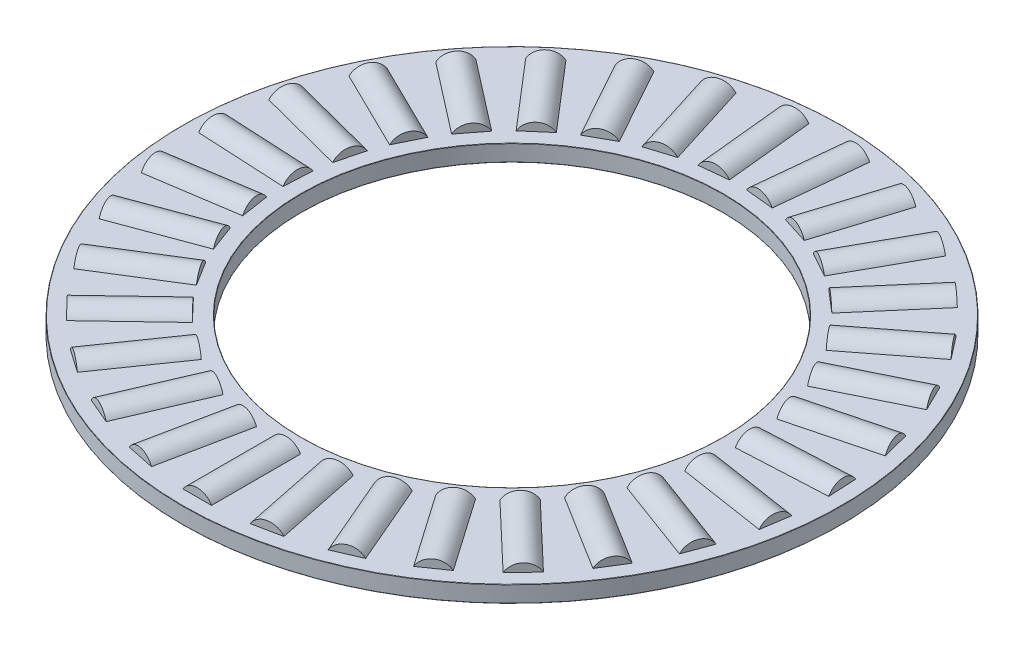
from build123d import *

# Parameters (mm, degrees)
SKETCH1_W         = 7.14375
SKETCH1_H         = 0.9921875
SKETCH3_W         = 5.3578125
SKETCH3_H         = 0.9921875
SKETCH2_W         = 5.3578125
SKETCH2_H         = 0.9921875
CIRPATTERN1_COUNT = 31
CIRPATTERN1_ANGLE = 348.387096774
CIRPATTERN2_COUNT = 31
FILLET2_R         = 0.01984375


with BuildPart() as part:
    # Sketch1 → Revolve1 (revolve)
    with BuildSketch(Plane(origin=(0, 0, 0), x_dir=(0, 0, -1), z_dir=(1, 0, 0)), mode=Mode.PRIVATE) as revolve1_sk:
        with Locations((-16.271875, 0)):
            Rectangle(SKETCH1_W, SKETCH1_H)
    revolve(revolve1_sk.sketch.rotate(Axis((0, -0.9921875, 0), (0, 1, 0)), 180), axis=Axis((0, -0.9921875, 0), (0, 1, 0)))

    # Sketch3 → Cut-Revolve1 (revolve, cut)
    with BuildSketch(Plane(origin=(0, 0, 0), x_dir=(0, 0, -1), z_dir=(1, 0, 0))):
        with Locations((-16.271875, 0.49609375)):
            Rectangle(SKETCH3_W, SKETCH3_H)
    cut_revolve1 = revolve(axis=Axis((0, 0, 18.95078125), (0, 0, -1)), mode=Mode.SUBTRACT)

    # CirPattern2: Cut-Revolve1 ×31 about axis
    cirpattern2_axis = Axis((0, 0, 0), (0, 1, 0))
    for i in range(1, CIRPATTERN2_COUNT):
        add(cut_revolve1.rotate(cirpattern2_axis, i * 360 / CIRPATTERN2_COUNT), mode=Mode.SUBTRACT)

    # Fillet2
    fillet2_edges = [part.edges().sort_by_distance(p)[0] for p in [
        (0, 0.49609375, 19.84375),
        (0, 0.49609375, 12.7),
        (0, -0.49609375, 12.7),
        (0, -0.49609375, 19.84375),
    ]]
    fillet(fillet2_edges, radius=FILLET2_R)


with BuildPart() as body_2:
    # Sketch2 → Revolve2 (revolve)
    with BuildSketch(Plane(origin=(0, 0, 0), x_dir=(0, 0, -1), z_dir=(1, 0, 0)), mode=Mode.PRIVATE) as revolve2_sk:
        with Locations((-16.271875, 0.49609375)):
            Rectangle(SKETCH2_W, SKETCH2_H)
    revolve(revolve2_sk.sketch.rotate(Axis((0, 0, 18.95078125), (0, 0, -1)), 90), axis=Axis((0, 0, 18.95078125), (0, 0, -1)))


with BuildPart() as cirpattern1_1:
    # CirPattern1: pattern copy
    add(body_2.part.rotate(Axis((0, 0.9921875, 0), (0, -1, 0)), 1 * CIRPATTERN1_ANGLE / (CIRPATTERN1_COUNT - 1)))


with BuildPart() as cirpattern1_2:
    # CirPattern1: pattern copy
    add(body_2.part.rotate(Axis((0, 0.9921875, 0), (0, -1, 0)), 2 * CIRPATTERN1_ANGLE / (CIRPATTERN1_COUNT - 1)))


with BuildPart() as cirpattern1_3:
    # CirPattern1: pattern copy
    add(body_2.part.rotate(Axis((0, 0.9921875, 0), (0, -1, 0)), 3 * CIRPATTERN1_ANGLE / (CIRPATTERN1_COUNT - 1)))


with BuildPart() as cirpattern1_4:
    # CirPattern1: pattern copy
    add(body_2.part.rotate(Axis((0, 0.9921875, 0), (0, -1, 0)), 4 * CIRPATTERN1_ANGLE / (CIRPATTERN1_COUNT - 1)))


with BuildPart() as cirpattern1_5:
    # CirPattern1: pattern copy
    add(body_2.part.rotate(Axis((0, 0.9921875, 0), (0, -1, 0)), 5 * CIRPATTERN1_ANGLE / (CIRPATTERN1_COUNT - 1)))


with BuildPart() as cirpattern1_6:
    # CirPattern1: pattern copy
    add(body_2.part.rotate(Axis((0, 0.9921875, 0), (0, -1, 0)), 6 * CIRPATTERN1_ANGLE / (CIRPATTERN1_COUNT - 1)))


with BuildPart() as cirpattern1_7:
    # CirPattern1: pattern copy
    add(body_2.part.rotate(Axis((0, 0.9921875, 0), (0, -1, 0)), 7 * CIRPATTERN1_ANGLE / (CIRPATTERN1_COUNT - 1)))


with BuildPart() as cirpattern1_8:
    # CirPattern1: pattern copy
    add(body_2.part.rotate(Axis((0, 0.9921875, 0), (0, -1, 0)), 8 * CIRPATTERN1_ANGLE / (CIRPATTERN1_COUNT - 1)))


with BuildPart() as cirpattern1_9:
    # CirPattern1: pattern copy
    add(body_2.part.rotate(Axis((0, 0.9921875, 0), (0, -1, 0)), 9 * CIRPATTERN1_ANGLE / (CIRPATTERN1_COUNT - 1)))


with BuildPart() as cirpattern1_10:
    # CirPattern1: pattern copy
    add(body_2.part.rotate(Axis((0, 0.9921875, 0), (0, -1, 0)), 10 * CIRPATTERN1_ANGLE / (CIRPATTERN1_COUNT - 1)))


with BuildPart() as cirpattern1_11:
    # CirPattern1: pattern copy
    add(body_2.part.rotate(Axis((0, 0.9921875, 0), (0, -1, 0)), 11 * CIRPATTERN1_ANGLE / (CIRPATTERN1_COUNT - 1)))


with BuildPart() as cirpattern1_12:
    # CirPattern1: pattern copy
    add(body_2.part.rotate(Axis((0, 0.9921875, 0), (0, -1, 0)), 12 * CIRPATTERN1_ANGLE / (CIRPATTERN1_COUNT - 1)))


with BuildPart() as cirpattern1_13:
    # CirPattern1: pattern copy
    add(body_2.part.rotate(Axis((0, 0.9921875, 0), (0, -1, 0)), 13 * CIRPATTERN1_ANGLE / (CIRPATTERN1_COUNT - 1)))


with BuildPart() as cirpattern1_14:
    # CirPattern1: pattern copy
    add(body_2.part.rotate(Axis((0, 0.9921875, 0), (0, -1, 0)), 14 * CIRPATTERN1_ANGLE / (CIRPATTERN1_COUNT - 1)))


with BuildPart() as cirpattern1_15:
    # CirPattern1: pattern copy
    add(body_2.part.rotate(Axis((0, 0.9921875, 0), (0, -1, 0)), 15 * CIRPATTERN1_ANGLE / (CIRPATTERN1_COUNT - 1)))


with BuildPart() as cirpattern1_16:
    # CirPattern1: pattern copy
    add(body_2.part.rotate(Axis((0, 0.9921875, 0), (0, -1, 0)), 16 * CIRPATTERN1_ANGLE / (CIRPATTERN1_COUNT - 1)))


with BuildPart() as cirpattern1_17:
    # CirPattern1: pattern copy
    add(body_2.part.rotate(Axis((0, 0.9921875, 0), (0, -1, 0)), 17 * CIRPATTERN1_ANGLE / (CIRPATTERN1_COUNT - 1)))


with BuildPart() as cirpattern1_18:
    # CirPattern1: pattern copy
    add(body_2.part.rotate(Axis((0, 0.9921875, 0), (0, -1, 0)), 18 * CIRPATTERN1_ANGLE / (CIRPATTERN1_COUNT - 1)))


with BuildPart() as cirpattern1_19:
    # CirPattern1: pattern copy
    add(body_2.part.rotate(Axis((0, 0.9921875, 0), (0, -1, 0)), 19 * CIRPATTERN1_ANGLE / (CIRPATTERN1_COUNT - 1)))


with BuildPart() as cirpattern1_20:
    # CirPattern1: pattern copy
    add(body_2.part.rotate(Axis((0, 0.9921875, 0), (0, -1, 0)), 20 * CIRPATTERN1_ANGLE / (CIRPATTERN1_COUNT - 1)))


with BuildPart() as cirpattern1_21:
    # CirPattern1: pattern copy
    add(body_2.part.rotate(Axis((0, 0.9921875, 0), (0, -1, 0)), 21 * CIRPATTERN1_ANGLE / (CIRPATTERN1_COUNT - 1)))


with BuildPart() as cirpattern1_22:
    # CirPattern1: pattern copy
    add(body_2.part.rotate(Axis((0, 0.9921875, 0), (0, -1, 0)), 22 * CIRPATTERN1_ANGLE / (CIRPATTERN1_COUNT - 1)))


with BuildPart() as cirpattern1_23:
    # CirPattern1: pattern copy
    add(body_2.part.rotate(Axis((0, 0.9921875, 0), (0, -1, 0)), 23 * CIRPATTERN1_ANGLE / (CIRPATTERN1_COUNT - 1)))


with BuildPart() as cirpattern1_24:
    # CirPattern1: pattern copy
    add(body_2.part.rotate(Axis((0, 0.9921875, 0), (0, -1, 0)), 24 * CIRPATTERN1_ANGLE / (CIRPATTERN1_COUNT - 1)))


with BuildPart() as cirpattern1_25:
    # CirPattern1: pattern copy
    add(body_2.part.rotate(Axis((0, 0.9921875, 0), (0, -1, 0)), 25 * CIRPATTERN1_ANGLE / (CIRPATTERN1_COUNT - 1)))


with BuildPart() as cirpattern1_26:
    # CirPattern1: pattern copy
    add(body_2.part.rotate(Axis((0, 0.9921875, 0), (0, -1, 0)), 26 * CIRPATTERN1_ANGLE / (CIRPATTERN1_COUNT - 1)))


with BuildPart() as cirpattern1_27:
    # CirPattern1: pattern copy
    add(body_2.part.rotate(Axis((0, 0.9921875, 0), (0, -1, 0)), 27 * CIRPATTERN1_ANGLE / (CIRPATTERN1_COUNT - 1)))


with BuildPart() as cirpattern1_28:
    # CirPattern1: pattern copy
    add(body_2.part.rotate(Axis((0, 0.9921875, 0), (0, -1, 0)), 28 * CIRPATTERN1_ANGLE / (CIRPATTERN1_COUNT - 1)))


with BuildPart() as cirpattern1_29:
    # CirPattern1: pattern copy
    add(body_2.part.rotate(Axis((0, 0.9921875, 0), (0, -1, 0)), 29 * CIRPATTERN1_ANGLE / (CIRPATTERN1_COUNT - 1)))


with BuildPart() as cirpattern1_30:
    # CirPattern1: pattern copy
    add(body_2.part.rotate(Axis((0, 0.9921875, 0), (0, -1, 0)), 30 * CIRPATTERN1_ANGLE / (CIRPATTERN1_COUNT - 1)))


solid = Compound([part.part, body_2.part, cirpattern1_1.part, cirpattern1_2.part, cirpattern1_3.part, cirpattern1_4.part, cirpattern1_5.part, cirpattern1_6.part, cirpattern1_7.part, cirpattern1_8.part, cirpattern1_9.part, cirpattern1_10.part, cirpattern1_11.part, cirpattern1_12.part, cirpattern1_13.part, cirpattern1_14.part, cirpattern1_15.part, cirpattern1_16.part, cirpattern1_17.part, cirpattern1_18.part, cirpattern1_19.part, cirpattern1_20.part, cirpattern1_21.part, cirpattern1_22.part, cirpattern1_23.part, cirpattern1_24.part, cirpattern1_25.part, cirpattern1_26.part, cirpattern1_27.part, cirpattern1_28.part, cirpattern1_29.part, cirpattern1_30.part])
